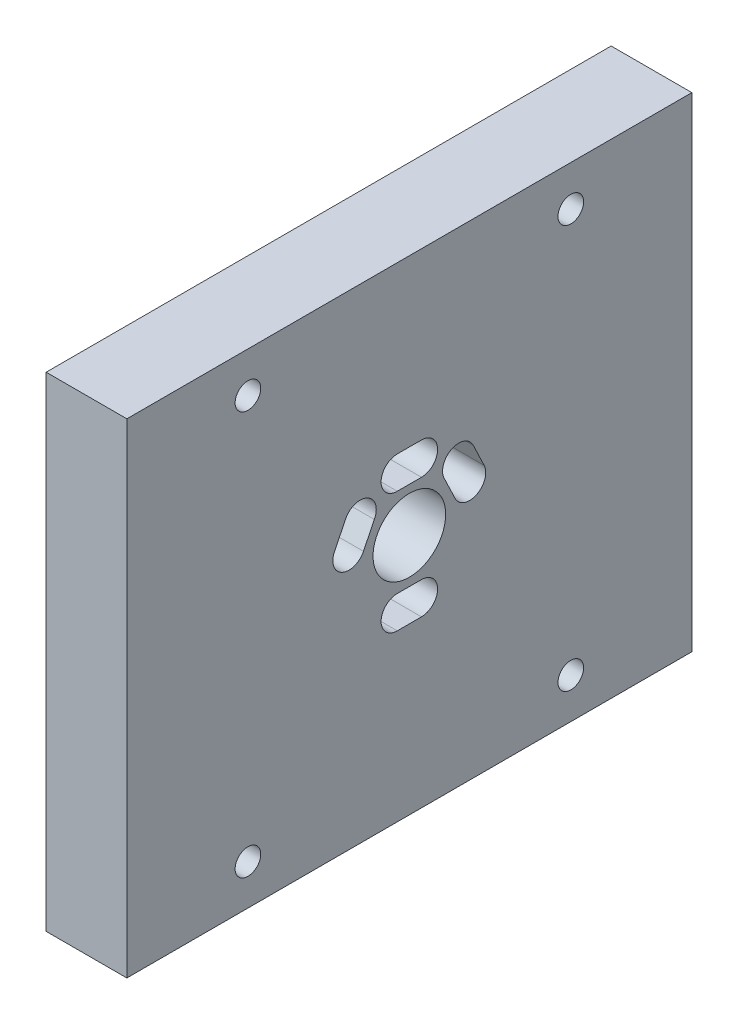
from build123d import *

# Parameters (mm, degrees)
SKETCH1_W           = 70
SKETCH1_H           = 60
SKETCH1_R           = 1.5875
SKETCH1_R_2         = 4.499999999
BOSS_EXTRUDE1_DEPTH = 10


with BuildPart() as part:
    # Sketch1 → Boss-Extrude1 (new body)
    with BuildSketch(Plane(origin=(0, 0, 0), x_dir=(0, 0, -1), z_dir=(1, 0, 0))):
        with Locations((3.813160791, 27.897530874)):
            Rectangle(SKETCH1_W, SKETCH1_H)
        with Locations((-16.186839209, 52.897530874)):
            Circle(SKETCH1_R, mode=Mode.SUBTRACT)
        with Locations((-16.186839209, 2.897530874)):
            Circle(SKETCH1_R, mode=Mode.SUBTRACT)
        with Locations((23.813160791, 2.897530874)):
            Circle(SKETCH1_R, mode=Mode.SUBTRACT)
        with Locations((23.813160791, 52.897530874)):
            Circle(SKETCH1_R, mode=Mode.SUBTRACT)
        with Locations((3.813160791, 27.897530874)):
            Circle(SKETCH1_R_2, mode=Mode.SUBTRACT)
        with BuildLine():
            Line((-5.464379102, 30.775341326), (-4.081605515, 33.606305024))
            ThreePointArc((-4.081605515, 33.606305024), (-1.369183898, 34.499769949), (-0.528409533, 31.770555947))
            Line((-0.528409533, 31.770555947), (-1.869576404, 29.020756356))
            ThreePointArc((-1.869576404, 29.020756356), (-4.544523089, 28.10012945), (-5.464379102, 30.775341326))
        make_face(mode=Mode.SUBTRACT)
        with BuildLine():
            Line((5.31316079, 18.397530874), (2.313160791, 18.397530874))
            ThreePointArc((2.313160791, 18.397530874), (0.313160792, 20.397530874), (2.313160791, 22.397530873))
            Line((2.313160791, 22.397530873), (5.31316079, 22.397530873))
            ThreePointArc((5.31316079, 22.397530873), (7.313160789, 20.397530874), (5.31316079, 18.397530874))
        make_face(mode=Mode.SUBTRACT)
        with BuildLine():
            Line((5.31316079, 33.374248764), (2.313160791, 33.374248764))
            ThreePointArc((2.313160791, 33.374248764), (0.31316079, 35.374248765), (2.313160791, 37.374248765))
            Line((2.313160791, 37.374248765), (5.31316079, 37.374248765))
            ThreePointArc((5.31316079, 37.374248765), (7.313160791, 35.374248765), (5.31316079, 33.374248764))
        make_face(mode=Mode.SUBTRACT)
        with BuildLine():
            Line((9.471997672, 29.038205562), (8.081045524, 31.961596177))
            ThreePointArc((8.081045524, 31.961596177), (9.113942414, 34.555839775), (11.733632625, 33.589300054))
            Line((11.733632625, 33.589300054), (13.083423708, 30.758314735))
            ThreePointArc((13.083423708, 30.758314735), (12.137765277, 28.092547131), (9.471997672, 29.038205562))
        make_face(mode=Mode.SUBTRACT)
    extrude(amount=BOSS_EXTRUDE1_DEPTH)


solid = part.part
